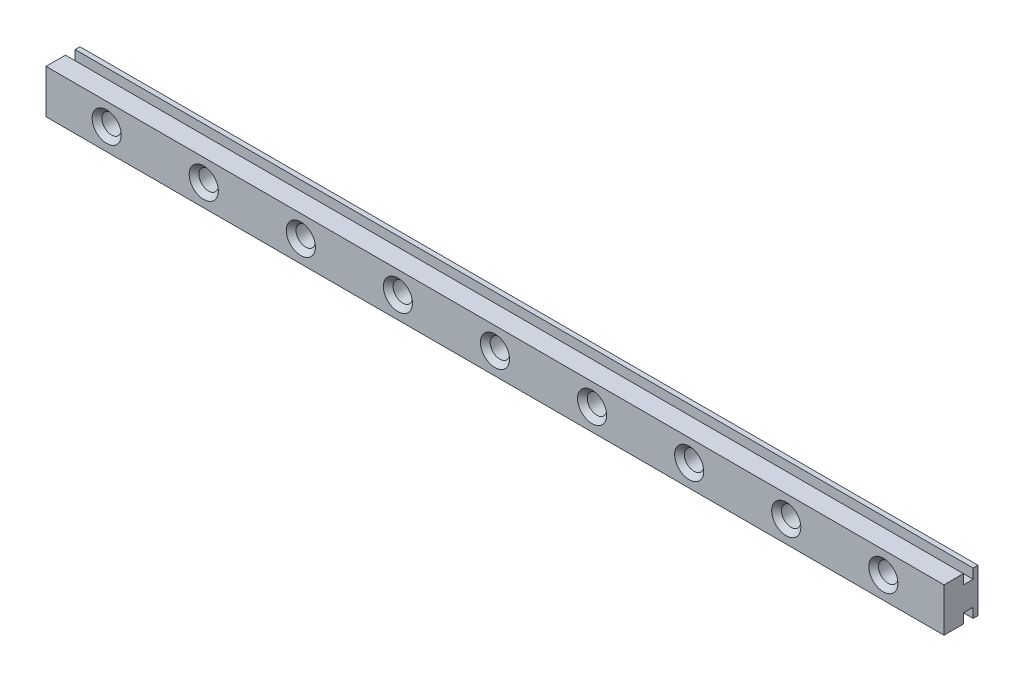
from build123d import *

# Parameters (mm, degrees)
ESQUISSE1_W             = 185
ESQUISSE1_H             = 9
ESQUISSE1_R             = 2
BOSS_EXTRU_1_DEPTH      = 7
ENL_V_MAT_EXTRU_1_REACH = 187
ESQUISSE2_W             = 2
ESQUISSE2_H             = 2
CHANFREIN1_SIZE         = 1


with BuildPart() as part:
    # Esquisse1 → Boss.-Extru.1 (new body)
    with BuildSketch(Plane.XY):
        Rectangle(ESQUISSE1_W, ESQUISSE1_H)
        with Locations((-80, 0)):
            Circle(ESQUISSE1_R, mode=Mode.SUBTRACT)
        with Locations((-60, 0)):
            Circle(ESQUISSE1_R, mode=Mode.SUBTRACT)
        with Locations((-40, 0)):
            Circle(ESQUISSE1_R, mode=Mode.SUBTRACT)
        with Locations((-20, 0)):
            Circle(ESQUISSE1_R, mode=Mode.SUBTRACT)
        Circle(ESQUISSE1_R, mode=Mode.SUBTRACT)
        with Locations((20, 0)):
            Circle(ESQUISSE1_R, mode=Mode.SUBTRACT)
        with Locations((40, 0)):
            Circle(ESQUISSE1_R, mode=Mode.SUBTRACT)
        with Locations((60, 0)):
            Circle(ESQUISSE1_R, mode=Mode.SUBTRACT)
        with Locations((80, 0)):
            Circle(ESQUISSE1_R, mode=Mode.SUBTRACT)
    extrude(amount=BOSS_EXTRU_1_DEPTH)

    # Esquisse2 → Enlèv. mat.-Extru.1 (cut, up to next)
    with BuildSketch(Plane.ZY.offset(92.5), mode=Mode.PRIVATE) as enl_v_mat_extru_1_sk1:
        with Locations((2, 3.5)):
            Rectangle(ESQUISSE2_W, ESQUISSE2_H)
    enl_v_mat_extru_1_tool1 = extrude(enl_v_mat_extru_1_sk1.sketch, amount=-ENL_V_MAT_EXTRU_1_REACH, mode=Mode.PRIVATE) & part.part
    add(enl_v_mat_extru_1_tool1.solids().sort_by_distance((-92.5, 3.5, 2))[0], mode=Mode.SUBTRACT)
    # Esquisse2 → Enlèv. mat.-Extru.1 (cut, up to next)
    with BuildSketch(Plane.ZY.offset(92.5), mode=Mode.PRIVATE) as enl_v_mat_extru_1_sk2:
        with Locations((2, -3.5)):
            Rectangle(ESQUISSE2_W, ESQUISSE2_H)
    enl_v_mat_extru_1_tool2 = extrude(enl_v_mat_extru_1_sk2.sketch, amount=-ENL_V_MAT_EXTRU_1_REACH, mode=Mode.PRIVATE) & part.part
    add(enl_v_mat_extru_1_tool2.solids().sort_by_distance((-92.5, -3.5, 2))[0], mode=Mode.SUBTRACT)

    # Chanfrein1
    chanfrein1_edges = [part.edges().sort_by_distance(p)[0] for p in [
        (-82, 0, 7),
        (-62, 0, 7),
        (-42, 0, 7),
        (-22, 0, 7),
        (-2, 0, 7),
        (18, 0, 7),
        (38, 0, 7),
        (58, 0, 7),
        (78, 0, 7),
    ]]
    chamfer(chanfrein1_edges, length=CHANFREIN1_SIZE)


solid = part.part
